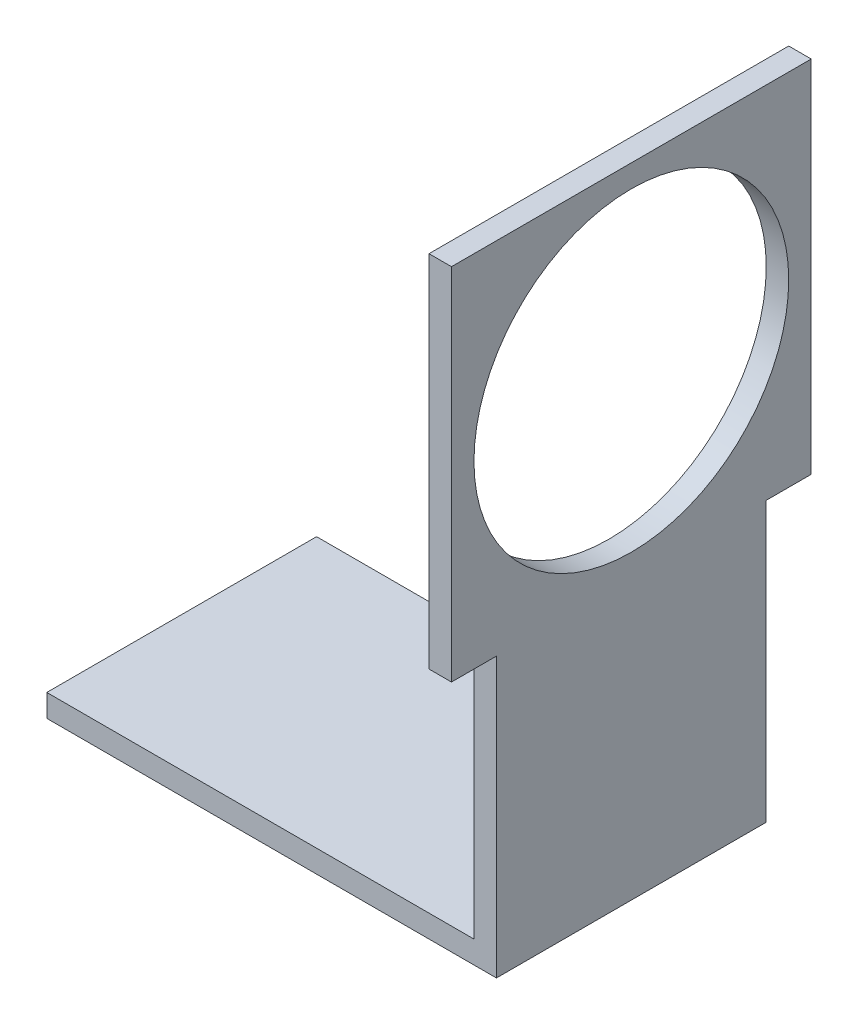
from build123d import *

# Parameters (mm, degrees)
SKETCH1_W           = 100
SKETCH1_H           = 60
BOSS_EXTRUDE1_DEPTH = 5
SKETCH2_W           = 5
SKETCH2_H           = 60
BOSS_EXTRUDE2_DEPTH = 57
BOSS_EXTRUDE3_DEPTH = 5
SKETCH5_R           = 35
CUT_EXTRUDE1_DEPTH  = 5


with BuildPart() as part:
    # Sketch1 → Boss-Extrude1 (new body)
    with BuildSketch(Plane(origin=(0, 0, 0), x_dir=(1, 0, 0), z_dir=(0, 1, 0))):
        with Locations((-43.057324841, 0.76433121)):
            Rectangle(SKETCH1_W, SKETCH1_H)
    extrude(amount=BOSS_EXTRUDE1_DEPTH)

    # Sketch2 → Boss-Extrude2 (add)
    with BuildSketch(Plane(origin=(0, 5, 0), x_dir=(1, 0, 0), z_dir=(0, 1, 0))):
        with Locations((4.442675159, 0.76433121)):
            Rectangle(SKETCH2_W, SKETCH2_H)
    extrude(amount=BOSS_EXTRUDE2_DEPTH)

    # Sketch4 → Boss-Extrude3 (add)
    with BuildSketch(Plane(origin=(6.942675159, 0, 0), x_dir=(0, 0, -1), z_dir=(1, 0, 0))):
        Polygon((-29.23566879, 62), (40.76433121, 62), (40.76433121, 142), (-39.23566879, 142), (-39.23566879, 62), align=None)
    extrude(amount=-BOSS_EXTRUDE3_DEPTH)

    # Sketch5 → Cut-Extrude1 (cut)
    with BuildSketch(Plane(origin=(6.942675159, 0, 0), x_dir=(0, 0, -1), z_dir=(1, 0, 0))):
        with Locations((0.76433121, 102)):
            Circle(SKETCH5_R)
    extrude(amount=-CUT_EXTRUDE1_DEPTH, mode=Mode.SUBTRACT)


solid = part.part
